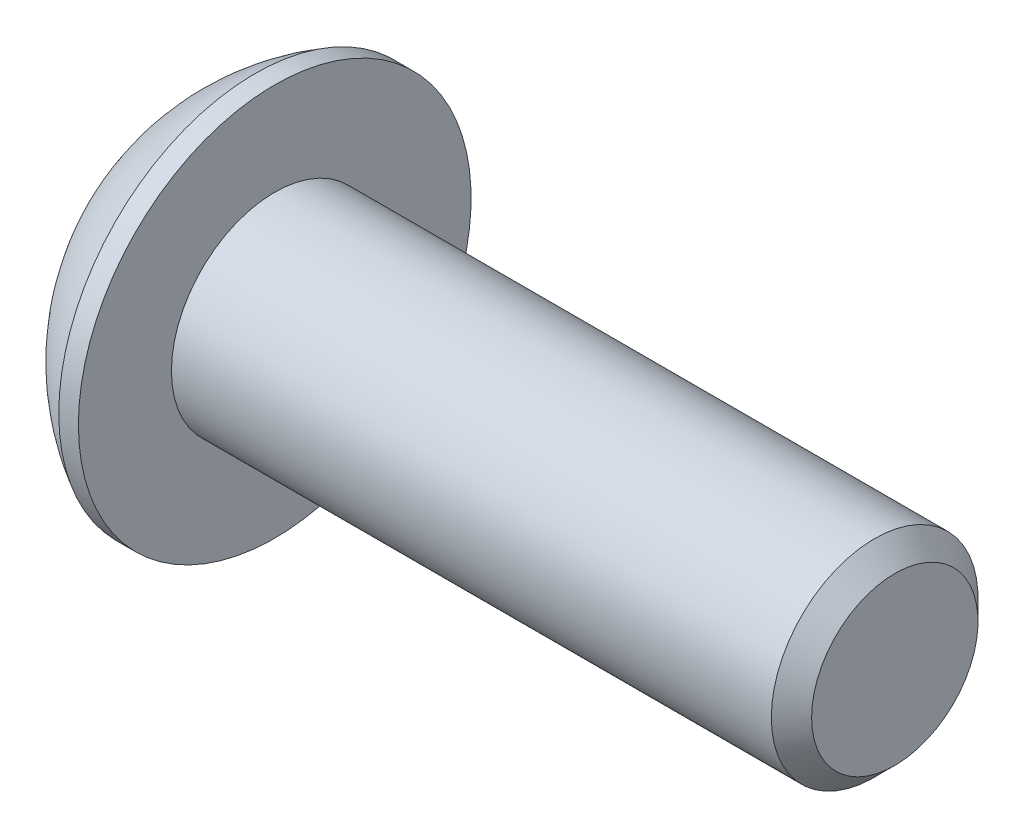
from build123d import *

# Parameters (mm, degrees)
CUT_EXTRUDE1_DEPTH = 1.3


with BuildPart() as part:
    # Sketch1 → Revolve1 (revolve)
    with BuildSketch(Plane.XY):
        with BuildLine():
            Line((14.2, 0), (14.2, 1.61))
            Line((14.2, 1.61), (13.81, 2))
            Line((13.81, 2), (2.2, 2))
            Line((2.2, 2), (2.2, 3.8))
            Line((2.2, 3.8), (1.82, 3.8))
            ThreePointArc((1.82, 3.8), (0.762013659, 2.991755338), (0, 1.9))
            Line((0, 1.9), (0, 0))
            Line((0, 0), (14.2, 0))
        make_face()
    revolve(axis=Axis((-2.02471666, 0, 0), (1, 0, 0)))

    # Sketch2 → Cut-Extrude1 (cut)
    with BuildSketch(Plane.ZY):
        Polygon((0.702687556, -1.260969814), (1.44337567, -0.021939633), (0.740688114, 1.239030181), (-0.702687556, 1.260969814), (-1.44337567, 0.021939633), (-0.740688114, -1.239030181), align=None)
    extrude(amount=-CUT_EXTRUDE1_DEPTH, mode=Mode.SUBTRACT)


solid = part.part
